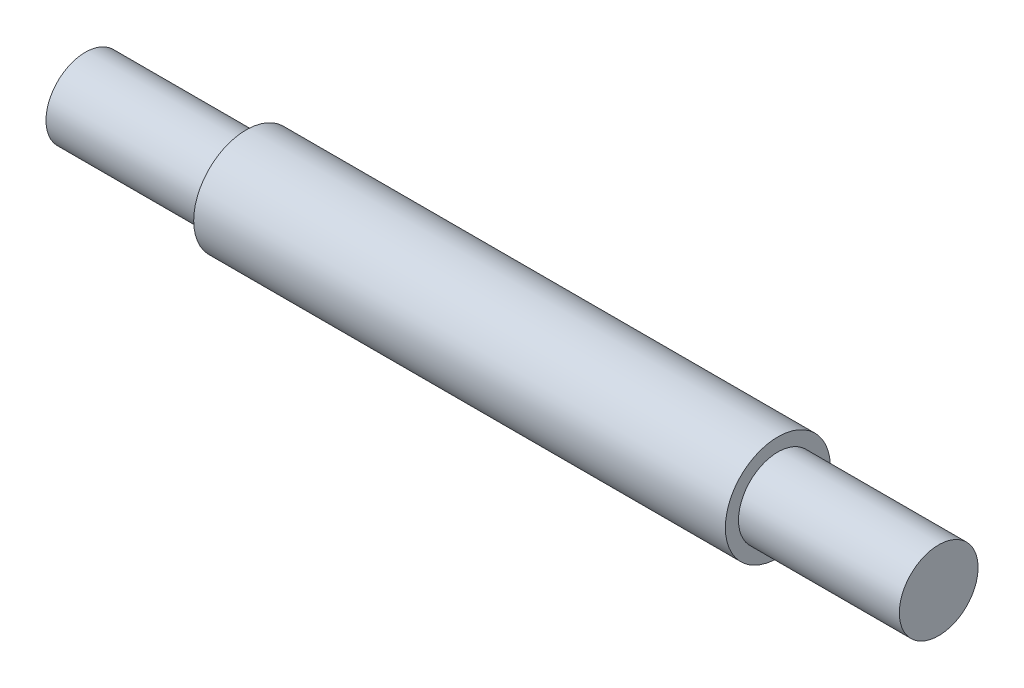
from build123d import *


with BuildPart() as part:
    # Sketch1 → Revolve1 (revolve)
    with BuildSketch(Plane.XY):
        Polygon((0, 0), (0, 8), (-40.5, 8), (-40.5, 6), (-65, 6), (-65, 0), align=None)
    revolve1 = revolve(axis=Axis((-65, 0, 0), (1, 0, 0)))

    # Mirror1: Revolve1 across plane
    add(revolve1.mirror(Plane.ZY))


solid = part.part
